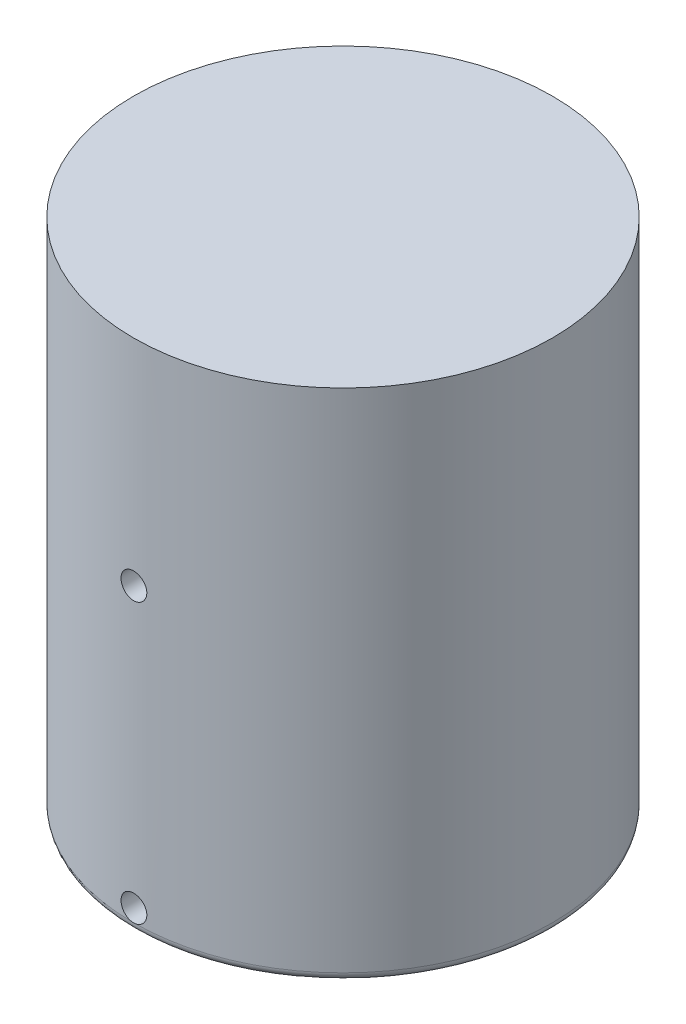
from build123d import *

# Parameters (mm, degrees)
SKETCH1_R                         = 6.1976
BOSS_EXTRUDE1_DEPTH               = 15.24
SKETCH2_R                         = 4.7625
CUT_EXTRUDE1_DEPTH                = 0.635
F_1_4_20_TAPPED_HOLE1_D           = 5.1054
F_1_4_20_TAPPED_HOLE1_DEPTH       = 7.62
F_1_4_20_TAPPED_HOLE1_CSINK_D     = 6.3754
F_1_4_20_TAPPED_HOLE1_CSINK_ANGLE = 90
F_1_4_20_TAPPED_HOLE1_TIP         = 1.533816902
FILLET4_R                         = 0.254
SKETCH7_R                         = 0.381
CUT_EXTRUDE2_DEPTH                = 18.580616962
CUT_EXTRUDE2_DEPTH_BACK           = 18.580616962


with BuildPart() as part:
    # Sketch1 → Boss-Extrude1 (new body)
    with BuildSketch(Plane(origin=(0, 0, 0), x_dir=(1, 0, 0), z_dir=(0, 1, 0))):
        with Locations(Location((0, 0, 0), (0, 0, 90))):
            Circle(SKETCH1_R)
    extrude(amount=BOSS_EXTRUDE1_DEPTH)

    # Sketch2 → Cut-Extrude1 (cut)
    with BuildSketch(Plane.XZ):
        with Locations(Location((0, 0, 0), (0, 0, 270))):
            Circle(SKETCH2_R)
    extrude(amount=-CUT_EXTRUDE1_DEPTH, mode=Mode.SUBTRACT)

    # 1/4-20 Tapped Hole1
    with Locations(Plane(origin=(0, 0.635, 0), x_dir=(-1, 0, 0), z_dir=(0, -1, 0))):
        with Locations((0, 0)):
            CounterSinkHole(F_1_4_20_TAPPED_HOLE1_D / 2, F_1_4_20_TAPPED_HOLE1_CSINK_D / 2, depth=F_1_4_20_TAPPED_HOLE1_DEPTH, counter_sink_angle=F_1_4_20_TAPPED_HOLE1_CSINK_ANGLE)
            with Locations((0, 0, -(F_1_4_20_TAPPED_HOLE1_DEPTH + F_1_4_20_TAPPED_HOLE1_TIP / 2))):  # 118° drill point
                Cone(0, F_1_4_20_TAPPED_HOLE1_D / 2, F_1_4_20_TAPPED_HOLE1_TIP, mode=Mode.SUBTRACT)

    # Fillet4
    fillet4_edges = [part.edges().sort_by_distance(p)[0] for p in [
        (0, 0, 6.1976),
    ]]
    fillet(fillet4_edges, radius=FILLET4_R)

    # Sketch7 → Cut-Extrude2 (cut, two sides)
    with BuildSketch(Plane.XY) as cut_extrude2_sk:
        with Locations(Location((0, 0.635, 0), (0, 0, 270))):
            Circle(SKETCH7_R)
        with Locations((0, 8.89)):
            Circle(SKETCH7_R)
    extrude(amount=CUT_EXTRUDE2_DEPTH, mode=Mode.SUBTRACT)
    extrude(cut_extrude2_sk.sketch, amount=-CUT_EXTRUDE2_DEPTH_BACK, mode=Mode.SUBTRACT)


solid = part.part
